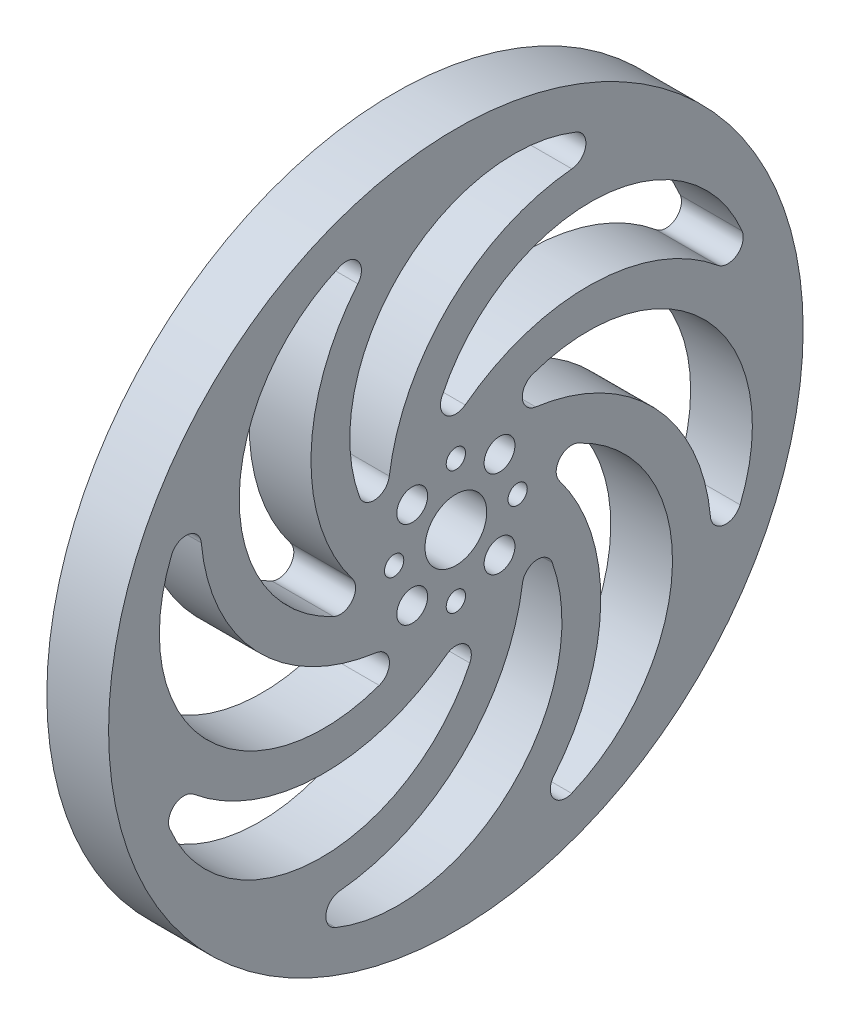
from build123d import *

# Parameters (mm, degrees)
SPROCKET_R                   = 45
ESTRUSIONE_ESTRUSIONE2_DEPTH = 8
SCHIZZO1_R                   = 4
SCHIZZO1_R_2                 = 2
SCHIZZO1_R_3                 = 1.25
TAGLIO_ESTRUSIONE2_DEPTH     = 9
TAGLIO_ESTRUSIONE3_DEPTH     = 9


with BuildPart() as part:
    # Sprocket → Estrusione-Estrusione2 (new body)
    with BuildSketch(Plane(origin=(0, 0, 0), x_dir=(0, 0, -1), z_dir=(1, 0, 0))):
        Circle(SPROCKET_R)
    extrude(amount=ESTRUSIONE_ESTRUSIONE2_DEPTH)

    # Schizzo1 → Taglio-Estrusione2 (cut, through all)
    with BuildSketch(Plane(origin=(0, 0, 0), x_dir=(0, 0, -1), z_dir=(1, 0, 0))):
        Circle(SCHIZZO1_R)
        with Locations((-5.656854249, 5.656854249)):
            Circle(SCHIZZO1_R_2)
        with Locations((5.656854249, 5.656854249)):
            Circle(SCHIZZO1_R_2)
        with Locations((0, 8)):
            Circle(SCHIZZO1_R_3)
        with Locations((8, 0)):
            Circle(SCHIZZO1_R_3)
        with Locations((-8, 0)):
            Circle(SCHIZZO1_R_3)
        with Locations((0, -8)):
            Circle(SCHIZZO1_R_3)
        with Locations((5.656854249, -5.656854249)):
            Circle(SCHIZZO1_R_2)
        with Locations((-5.656854249, -5.656854249)):
            Circle(SCHIZZO1_R_2)
    extrude(amount=TAGLIO_ESTRUSIONE2_DEPTH, mode=Mode.SUBTRACT)

    # Schizzo2 → Taglio-Estrusione3 (cut, through all)
    with BuildSketch(Plane(origin=(8, 0, 0), x_dir=(0, 0, -1), z_dir=(1, 0, 0))):
        with BuildLine():
            ThreePointArc((10.336761524, 8.624888754), (25.791574711, 0.750648199), (32.987627274, -15.031358723))
            ThreePointArc((32.987627274, -15.031358723), (34.683367414, -16.825784979), (36.829895727, -15.605983186))
            ThreePointArc((36.829895727, -15.605983186), (32.508005906, 7.181633564), (9.929440233, 12.488476401))
            ThreePointArc((9.929440233, 12.488476401), (8.617624488, 10.396912474), (10.336761524, 8.624888754))
        make_face()
        with BuildLine():
            ThreePointArc((-1.809511828, 15.851860872), (-1.2581466, 13.445308027), (1.210476844, 13.407911494))
            ThreePointArc((1.210476844, 13.407911494), (17.706608944, 18.768185808), (33.954550624, 12.696999257))
            ThreePointArc((33.954550624, 12.696999257), (36.42247095, 12.627217636), (37.077765557, 15.007572481))
            ThreePointArc((37.077765557, 15.007572481), (17.908449626, 28.064813212), (-1.809511828, 15.851860872))
        make_face()
        with BuildLine():
            ThreePointArc((13.407911494, -1.210476844), (18.768185808, -17.706608944), (12.696999257, -33.954550624))
            ThreePointArc((12.696999257, -33.954550624), (12.627217636, -36.42247095), (15.007572481, -37.077765557))
            ThreePointArc((15.007572481, -37.077765557), (28.064813212, -17.908449626), (15.851860872, 1.809511828))
            ThreePointArc((15.851860872, 1.809511828), (13.445308027, 1.2581466), (13.407911494, -1.210476844))
        make_face()
        with BuildLine():
            ThreePointArc((8.624888754, -10.336761524), (0.750648199, -25.791574711), (-15.031358723, -32.987627274))
            ThreePointArc((-15.031358723, -32.987627274), (-16.825784979, -34.683367414), (-15.605983186, -36.829895727))
            ThreePointArc((-15.605983186, -36.829895727), (7.181633564, -32.508005906), (12.488476401, -9.929440233))
            ThreePointArc((12.488476401, -9.929440233), (10.396912474, -8.617624488), (8.624888754, -10.336761524))
        make_face()
        with BuildLine():
            ThreePointArc((-1.210476844, -13.407911494), (-17.706608944, -18.768185808), (-33.954550624, -12.696999257))
            ThreePointArc((-33.954550624, -12.696999257), (-36.42247095, -12.627217636), (-37.077765557, -15.007572481))
            ThreePointArc((-37.077765557, -15.007572481), (-17.908449626, -28.064813212), (1.809511828, -15.851860872))
            ThreePointArc((1.809511828, -15.851860872), (1.2581466, -13.445308027), (-1.210476844, -13.407911494))
        make_face()
        with BuildLine():
            ThreePointArc((-10.336761524, -8.624888754), (-25.791574711, -0.750648199), (-32.987627274, 15.031358723))
            ThreePointArc((-32.987627274, 15.031358723), (-34.683367414, 16.825784979), (-36.829895727, 15.605983186))
            ThreePointArc((-36.829895727, 15.605983186), (-32.508005906, -7.181633564), (-9.929440233, -12.488476401))
            ThreePointArc((-9.929440233, -12.488476401), (-8.617624488, -10.396912474), (-10.336761524, -8.624888754))
        make_face()
        with BuildLine():
            ThreePointArc((-13.407911494, 1.210476844), (-18.768185808, 17.706608944), (-12.696999257, 33.954550624))
            ThreePointArc((-12.696999257, 33.954550624), (-12.627217636, 36.42247095), (-15.007572481, 37.077765557))
            ThreePointArc((-15.007572481, 37.077765557), (-28.064813212, 17.908449626), (-15.851860872, -1.809511828))
            ThreePointArc((-15.851860872, -1.809511828), (-13.445308027, -1.2581466), (-13.407911494, 1.210476844))
        make_face()
        with BuildLine():
            ThreePointArc((-8.624888754, 10.336761524), (-0.750648199, 25.791574711), (15.031358723, 32.987627274))
            ThreePointArc((15.031358723, 32.987627274), (16.825784979, 34.683367414), (15.605983186, 36.829895727))
            ThreePointArc((15.605983186, 36.829895727), (-7.181633564, 32.508005906), (-12.488476401, 9.929440233))
            ThreePointArc((-12.488476401, 9.929440233), (-10.396912474, 8.617624488), (-8.624888754, 10.336761524))
        make_face()
    extrude(amount=-TAGLIO_ESTRUSIONE3_DEPTH, mode=Mode.SUBTRACT)


solid = part.part
